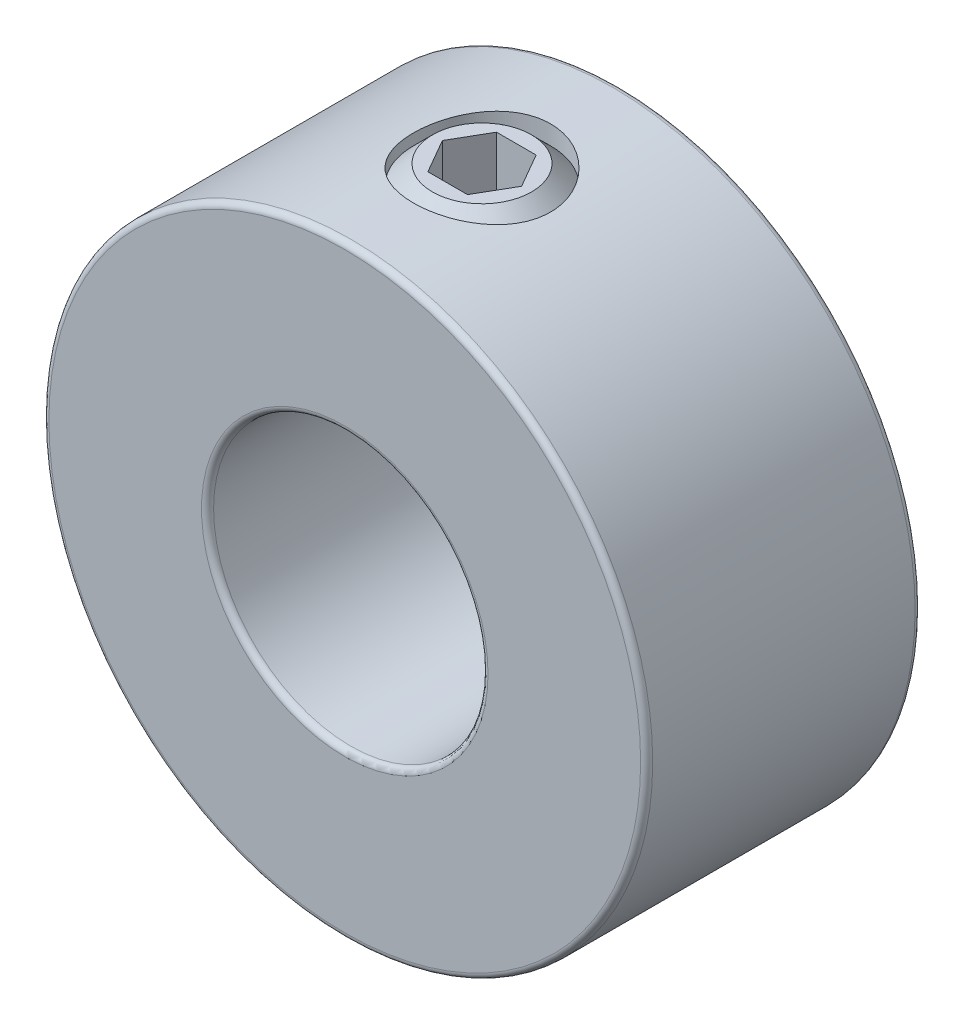
from build123d import *

# Parameters (mm, degrees)
SKETCH1_R          = 11
SKETCH1_R_2        = 5
EXTRUDE1_DEPTH     = 10
CUT_EXTRUDE1_REACH = 24
SKETCH2_R          = 2.5
CUT_EXTRUDE2_DEPTH = 2
FILLET1_R          = 0.22


with BuildPart() as part:
    # Sketch1 → Extrude1 (new body)
    with BuildSketch(Plane.XY):
        Circle(SKETCH1_R)
        Circle(SKETCH1_R_2, mode=Mode.SUBTRACT)
    extrude(amount=EXTRUDE1_DEPTH)

    # Sketch2 → Cut-Extrude1 (cut, up to next)
    with BuildSketch(Plane(origin=(0, 11, 0), x_dir=(-1, 0, 0), z_dir=(0, 1, 0)), mode=Mode.PRIVATE) as cut_extrude1_sk1:
        with Locations((0, 5)):
            Circle(SKETCH2_R)
    cut_extrude1_tool1 = extrude(cut_extrude1_sk1.sketch, amount=-CUT_EXTRUDE1_REACH, mode=Mode.PRIVATE) & part.part
    add(cut_extrude1_tool1.solids().sort_by_distance((0, 11, 5))[0], mode=Mode.SUBTRACT)

    # Fillet1
    fillet1_edges = [part.edges().sort_by_distance(p)[0] for p in [
        (-11, 0, 0),
        (-11, 0, 10),
        (-5, 0, 0),
        (-5, 0, 10),
    ]]
    fillet(fillet1_edges, radius=FILLET1_R)


with BuildPart() as body_2:
    # Sketch3 → Revolve1 (revolve)
    with BuildSketch(Plane.XY.offset(5)):
        Polygon((-1.804219591, 11), (-2.5, 10.304219591), (-2.5, 6.695780409), (-1.804219591, 6), (-0.625, 6), (0, 7.082531755), (0, 11), align=None)
    revolve(axis=Axis((0, 7.082531755, 5), (0, 1, 0)))

    # Sketch4 → Cut-Extrude2 (cut)
    with BuildSketch(Plane(origin=(0, 11, 0), x_dir=(0, 0, -1), z_dir=(0, 1, 0))):
        Polygon((-5, 1.443375673), (-6.25, 0.721687836), (-6.25, -0.721687836), (-5, -1.443375673), (-3.75, -0.721687836), (-3.75, 0.721687836), align=None)
    extrude(amount=-CUT_EXTRUDE2_DEPTH, mode=Mode.SUBTRACT)


solid = Compound([part.part, body_2.part])
